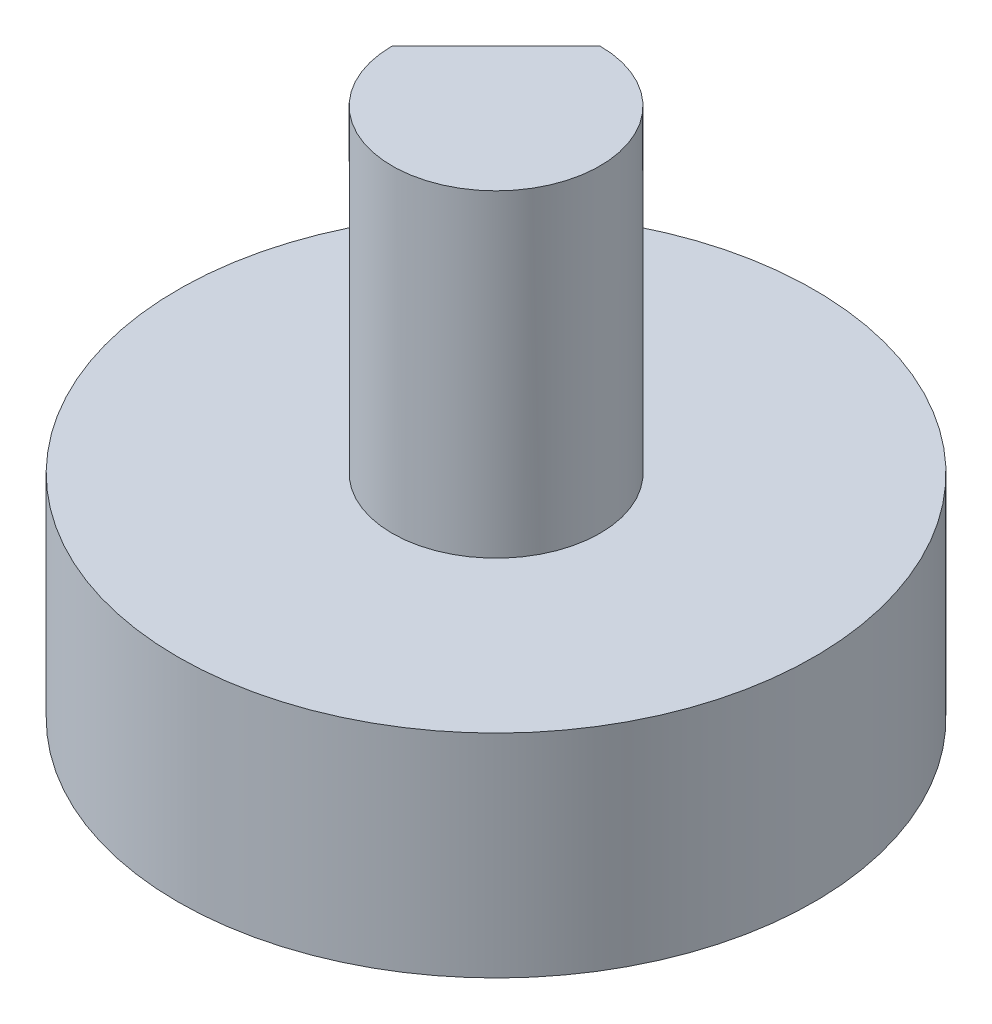
from build123d import *

# Parameters (mm, degrees)
SKETCH1_R           = 15
BOSS_EXTRUDE1_DEPTH = 10
SKETCH2_R           = 4.9
BOSS_EXTRUDE2_DEPTH = 15
CUT_EXTRUDE1_DEPTH  = 4


with BuildPart() as part:
    # Sketch1 → Boss-Extrude1 (new body)
    with BuildSketch(Plane(origin=(0, 0, 0), x_dir=(1, 0, 0), z_dir=(0, 1, 0))):
        Circle(SKETCH1_R)
    extrude(amount=BOSS_EXTRUDE1_DEPTH)

    # Sketch2 → Boss-Extrude2 (add)
    with BuildSketch(Plane(origin=(0, 10, 0), x_dir=(1, 0, 0), z_dir=(0, 1, 0))):
        Circle(SKETCH2_R)
    extrude(amount=BOSS_EXTRUDE2_DEPTH)

    # Sketch3 → Cut-Extrude1 (cut)
    with BuildSketch(Plane(origin=(0, 25, 0), x_dir=(1, 0, 0), z_dir=(0, 1, 0))):
        with BuildLine():
            Line((-4.9, 0), (0, 4.9))
            ThreePointArc((0, 4.9), (-3.464823228, 3.464823228), (-4.9, 0))
        make_face()
    extrude(amount=-CUT_EXTRUDE1_DEPTH, mode=Mode.SUBTRACT)


solid = part.part
